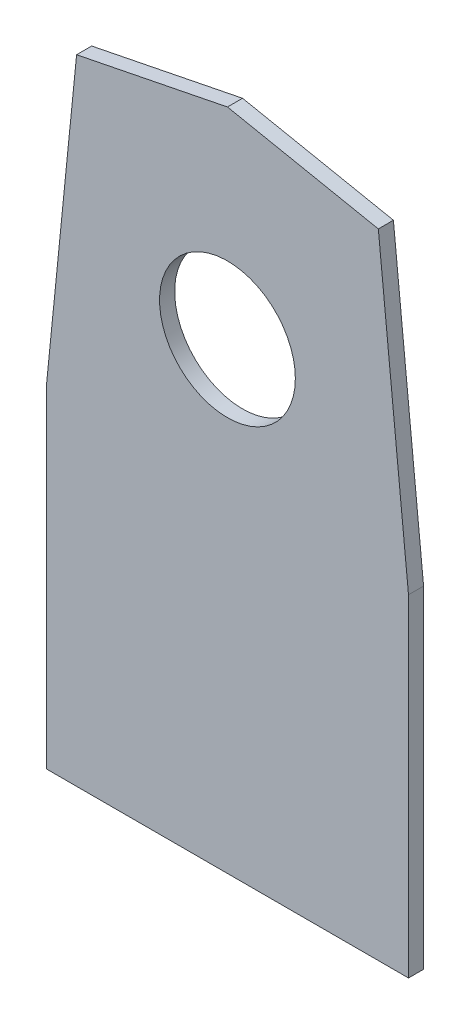
from build123d import *

# Parameters (mm, degrees)
BOSS_EXTRUDE1_DEPTH = 3.175
SKETCH2_R           = 14.2875
CUT_EXTRUDE1_DEPTH  = 3.175


with BuildPart() as part:
    # Sketch1 → Boss-Extrude1 (new body)
    with BuildSketch(Plane.XY):
        Polygon((36.180133555, -50.152996979), (36.180133555, 19.697003021), (29.830133555, 83.197003021), (-1.919866445, 89.547003021), (-33.669866445, 83.197003021), (-40.019866445, 19.697003021), (-40.019866445, -50.152996979), align=None)
    extrude(amount=BOSS_EXTRUDE1_DEPTH)

    # Sketch2 → Cut-Extrude1 (cut)
    with BuildSketch(Plane.XY.offset(3.175)):
        with Locations((-1.919866445, 47.205203021)):
            Circle(SKETCH2_R)
    extrude(amount=-CUT_EXTRUDE1_DEPTH, mode=Mode.SUBTRACT)


solid = part.part
